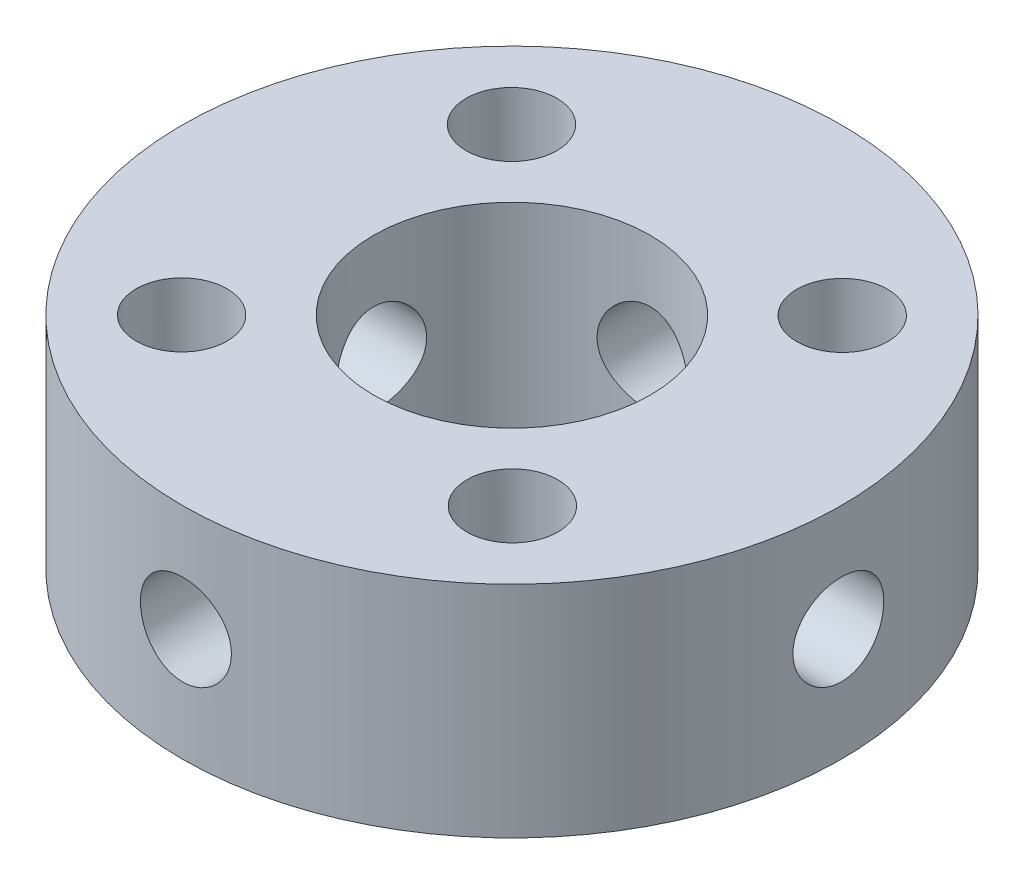
from build123d import *

# Parameters (mm, degrees)
SKETCH1_R                                  = 38.1
SKETCH1_R_2                                = 16
BOSS_EXTRUDE1_DEPTH                        = 25.4
F_10_5_10_5_DIAMETER_HOLE1_D               = 10.5
F_10_5_10_5_DIAMETER_HOLE1_DEPTH           = 300
F_10_5_10_5_DIAMETER_HOLE1_TIP             = 3.15451825
F_10_5_10_5_DIAMETER_HOLE1_ON_FACE_2_D     = 10.5
F_10_5_10_5_DIAMETER_HOLE1_ON_FACE_2_DEPTH = 300
F_10_5_10_5_DIAMETER_HOLE1_ON_FACE_2_TIP   = 3.15451825
F_10_5_10_5_DIAMETER_HOLE1_ON_FACE_3_D     = 10.5
F_10_5_10_5_DIAMETER_HOLE1_ON_FACE_3_DEPTH = 300
F_10_5_10_5_DIAMETER_HOLE1_ON_FACE_3_TIP   = 3.15451825


with BuildPart() as part:
    # Sketch1 → Boss-Extrude1 (new body)
    with BuildSketch(Plane(origin=(0, 0, 0), x_dir=(1, 0, 0), z_dir=(0, 1, 0))):
        Circle(SKETCH1_R)
        Circle(SKETCH1_R_2, mode=Mode.SUBTRACT)
    extrude(amount=BOSS_EXTRUDE1_DEPTH)

    # Ø10.5 (10.5) Diameter Hole1
    with Locations(Plane(origin=(-0.05014739, 13, -38.099966998), x_dir=(-0.999999134, 0, 0.001316204), z_dir=(-0.001316204, 0, -0.999999134))):
        with Locations((0, 0)):
            Hole(F_10_5_10_5_DIAMETER_HOLE1_D / 2, depth=F_10_5_10_5_DIAMETER_HOLE1_DEPTH)
            with Locations((0, 0, -(F_10_5_10_5_DIAMETER_HOLE1_DEPTH + F_10_5_10_5_DIAMETER_HOLE1_TIP / 2))):  # 118° drill point
                Cone(0, F_10_5_10_5_DIAMETER_HOLE1_D / 2, F_10_5_10_5_DIAMETER_HOLE1_TIP, mode=Mode.SUBTRACT)

    # Ø10.5 (10.5) Diameter Hole1 on face 2
    with Locations(Plane(origin=(-38.1, 13, 0), x_dir=(0, 0, -1), z_dir=(-1, 0, 0))):
        with Locations((0, 0)):
            Hole(F_10_5_10_5_DIAMETER_HOLE1_ON_FACE_2_D / 2, depth=F_10_5_10_5_DIAMETER_HOLE1_ON_FACE_2_DEPTH)
            with Locations((0, 0, -(F_10_5_10_5_DIAMETER_HOLE1_ON_FACE_2_DEPTH + F_10_5_10_5_DIAMETER_HOLE1_ON_FACE_2_TIP / 2))):  # 118° drill point
                Cone(0, F_10_5_10_5_DIAMETER_HOLE1_ON_FACE_2_D / 2, F_10_5_10_5_DIAMETER_HOLE1_ON_FACE_2_TIP, mode=Mode.SUBTRACT)

    # Ø10.5 (10.5) Diameter Hole1 on face 3
    with Locations(Plane(origin=(19.117815044, 0, -19.06591587), x_dir=(0, 0, -1), z_dir=(0, -1, 0))):
        with Locations((0, 0), (0, -38.235630088), (-38.13183174, -38.235630088), (-38.13183174, 0)):
            Hole(F_10_5_10_5_DIAMETER_HOLE1_ON_FACE_3_D / 2, depth=F_10_5_10_5_DIAMETER_HOLE1_ON_FACE_3_DEPTH)
            with Locations((0, 0, -(F_10_5_10_5_DIAMETER_HOLE1_ON_FACE_3_DEPTH + F_10_5_10_5_DIAMETER_HOLE1_ON_FACE_3_TIP / 2))):  # 118° drill point
                Cone(0, F_10_5_10_5_DIAMETER_HOLE1_ON_FACE_3_D / 2, F_10_5_10_5_DIAMETER_HOLE1_ON_FACE_3_TIP, mode=Mode.SUBTRACT)


solid = part.part
